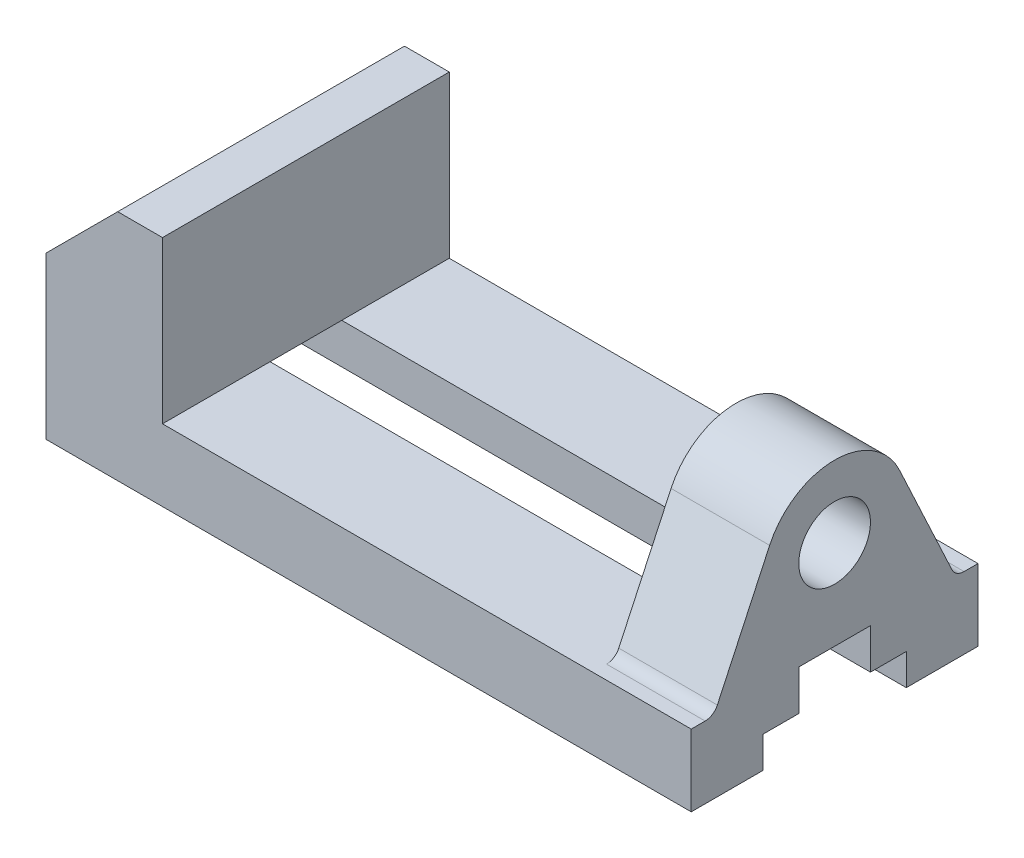
from build123d import *

# Parameters (mm, degrees)
BOSS_EXTRUDE1_DEPTH = 64
SKETCH2_R           = 8
CUT_EXTRUDE1_DEPTH  = 64
CUT_EXTRUDE2_REACH  = 146
SKETCH4_R           = 3
CUT_EXTRUDE3_DEPTH  = 10


with BuildPart() as part:
    # Sketch1 → Boss-Extrude1 (new body)
    with BuildSketch(Plane.XY):
        Polygon((0, 0), (144, 0), (144, 52), (122, 52), (122, 16), (26, 16), (26, 52), (16, 52), (0, 36), align=None)
    extrude(amount=BOSS_EXTRUDE1_DEPTH)

    # Sketch2 → Cut-Extrude1 (cut)
    with BuildSketch(Plane(origin=(144, 0, 0), x_dir=(0, 0, -1), z_dir=(1, 0, 0))):
        with BuildLine():
            Line((-64, 52), (-64, 16))
            Line((-64, 16), (-60.891410649, 16))
            ThreePointArc((-60.891410649, 16), (-59.279511824, 16.469825663), (-58.172487288, 17.732145215))
            Line((-58.172487288, 17.732145215), (-46.500924593, 42.761892188))
            ThreePointArc((-46.500924593, 42.761892188), (-40.596793734, 49.494263133), (-32, 52))
            Line((-32, 52), (-64, 52))
        make_face()
        with BuildLine():
            Line((0, 52), (-32, 52))
            ThreePointArc((-32, 52), (-23.403206266, 49.494263133), (-17.499075407, 42.761892188))
            Line((-17.499075407, 42.761892188), (-5.827512712, 17.732145215))
            ThreePointArc((-5.827512712, 17.732145215), (-4.720488176, 16.469825663), (-3.108589351, 16))
            Line((-3.108589351, 16), (0, 16))
            Line((0, 16), (0, 52))
        make_face()
        with Locations((-32, 36)):
            Circle(SKETCH2_R)
    extrude(amount=-CUT_EXTRUDE1_DEPTH, mode=Mode.SUBTRACT)

    # Sketch3 → Cut-Extrude2 (cut, up to next)
    with BuildSketch(Plane(origin=(144, 0, 0), x_dir=(0, 0, -1), z_dir=(1, 0, 0)), mode=Mode.PRIVATE) as cut_extrude2_sk1:
        Polygon((-48, 0), (-16, 0), (-16, 7), (-24, 7), (-24, 16), (-40, 16), (-40, 7), (-48, 7), align=None)
    cut_extrude2_tool1 = extrude(cut_extrude2_sk1.sketch, amount=-CUT_EXTRUDE2_REACH, mode=Mode.PRIVATE) & part.part
    add(cut_extrude2_tool1.solids().sort_by_distance((144, 6.630435, 32))[0], mode=Mode.SUBTRACT)

    # Sketch4 → Cut-Extrude3 (cut)
    with BuildSketch(Plane.XZ):
        with Locations((36, 54)):
            Circle(SKETCH4_R)
        with Locations((106, 54)):
            Circle(SKETCH4_R)
        with Locations((36, 10)):
            Circle(SKETCH4_R)
        with Locations((106, 10)):
            Circle(SKETCH4_R)
    extrude(amount=-CUT_EXTRUDE3_DEPTH, mode=Mode.SUBTRACT)


solid = part.part
